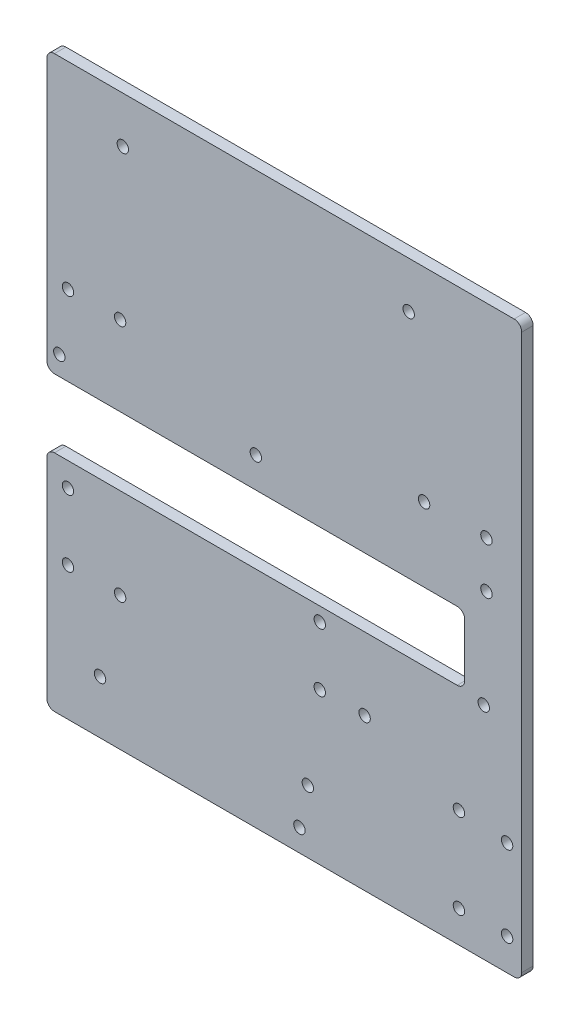
from build123d import *

# Parameters (mm, degrees)
SKETCH_1_W          = 125
SKETCH_1_H          = 100
SKETCH_1_R          = 1.5
EXTRUDE_1_DEPTH     = 3
SKETCH_2_W          = 110
SKETCH_2_H          = 18
CUT_EXTRUDE_1_DEPTH = 4
SKETCH_3_W          = 125
SKETCH_3_H          = 3
EXTRUDE_2_DEPTH     = 50
SKETCH_4_R          = 1.5
CUT_EXTRUDE_2_DEPTH = 4
FILLET_1_R          = 2


with BuildPart() as part:
    # 草图1 → 凸台-拉伸1 (new body)
    with BuildSketch(Plane.XY):
        with Locations((19.853937426, -18.887566332)):
            Rectangle(SKETCH_1_W, SKETCH_1_H)
        with Locations((-37.096062574, 29.132433668)):
            Circle(SKETCH_1_R, mode=Mode.SUBTRACT)
        with Locations((-23.366062574, 29.132433668)):
            Circle(SKETCH_1_R, mode=Mode.SUBTRACT)
        with Locations((-39.376062574, 13.182433668)):
            Circle(SKETCH_1_R, mode=Mode.SUBTRACT)
        with Locations((-37.096062574, -16.197566332)):
            Circle(SKETCH_1_R, mode=Mode.SUBTRACT)
        with Locations((-37.096062574, -33.707566332)):
            Circle(SKETCH_1_R, mode=Mode.SUBTRACT)
        with Locations((-23.366062574, -33.707566332)):
            Circle(SKETCH_1_R, mode=Mode.SUBTRACT)
        with Locations((56.653937426, 27.572433668)):
            Circle(SKETCH_1_R, mode=Mode.SUBTRACT)
        with Locations((73.063937426, 27.572433668)):
            Circle(SKETCH_1_R, mode=Mode.SUBTRACT)
        with Locations((73.063937426, 15.362433668)):
            Circle(SKETCH_1_R, mode=Mode.SUBTRACT)
        with Locations((29.193937426, -13.557566332)):
            Circle(SKETCH_1_R, mode=Mode.SUBTRACT)
        with Locations((29.193937426, -28.967566332)):
            Circle(SKETCH_1_R, mode=Mode.SUBTRACT)
        with Locations((40.993937426, -28.967566332)):
            Circle(SKETCH_1_R, mode=Mode.SUBTRACT)
        with Locations((26.043937426, -52.367566332)):
            Circle(SKETCH_1_R, mode=Mode.SUBTRACT)
        with Locations((23.833937426, -63.057566332)):
            Circle(SKETCH_1_R, mode=Mode.SUBTRACT)
        with Locations((65.823937426, -60.517566332)):
            Circle(SKETCH_1_R, mode=Mode.SUBTRACT)
        with Locations((78.503937426, -60.517566332)):
            Circle(SKETCH_1_R, mode=Mode.SUBTRACT)
        with Locations((78.503937426, -39.267566332)):
            Circle(SKETCH_1_R, mode=Mode.SUBTRACT)
        with Locations((65.823937426, -38.177566332)):
            Circle(SKETCH_1_R, mode=Mode.SUBTRACT)
        with Locations((-28.646062574, -54.887566332)):
            Circle(SKETCH_1_R, mode=Mode.SUBTRACT)
        with Locations((72.353937426, -10.887566332)):
            Circle(SKETCH_1_R, mode=Mode.SUBTRACT)
        with Locations((12.353937426, 16.112433668)):
            Circle(SKETCH_1_R, mode=Mode.SUBTRACT)
    extrude(amount=EXTRUDE_1_DEPTH)

    # 草图2 → 切除-拉伸1 (cut, through all)
    with BuildSketch(Plane(origin=(0, 0, 0), x_dir=(-1, 0, 0), z_dir=(0, 0, -1))):
        with Locations((-12.353937426, -0.887566332)):
            Rectangle(SKETCH_2_W, SKETCH_2_H)
    extrude(amount=-CUT_EXTRUDE_1_DEPTH, mode=Mode.SUBTRACT)

    # 草图3 → 凸台-拉伸2 (add)
    with BuildSketch(Plane(origin=(0, 31.112433668, 0), x_dir=(1, 0, 0), z_dir=(0, 1, 0))):
        with Locations((19.853937426, -1.5)):
            Rectangle(SKETCH_3_W, SKETCH_3_H)
    extrude(amount=EXTRUDE_2_DEPTH)

    # 草图4 → 切除-拉伸2 (cut, through all)
    with BuildSketch(Plane(origin=(0, 0, 0), x_dir=(-1, 0, 0), z_dir=(0, 0, -1))):
        with Locations((-52.603937426, 68.922433668)):
            Circle(SKETCH_4_R)
        with Locations((22.656062574, 68.922433668)):
            Circle(SKETCH_4_R)
    extrude(amount=-CUT_EXTRUDE_2_DEPTH, mode=Mode.SUBTRACT)

    # 圆角1
    fillet_1_edges = [part.edges().sort_by_distance(p)[0] for p in [
        (-42.646062574, 8.112433668, 1.5),
        (-42.646062574, -9.887566332, 1.5),
        (67.353937426, -9.887566332, 1.5),
        (67.353937426, 8.112433668, 1.5),
        (-42.646062574, 81.112433668, 1.5),
        (82.353937426, 81.112433668, 1.5),
        (82.353937426, -68.887566332, 1.5),
        (-42.646062574, -68.887566332, 1.5),
    ]]
    fillet(fillet_1_edges, radius=FILLET_1_R)


solid = part.part
